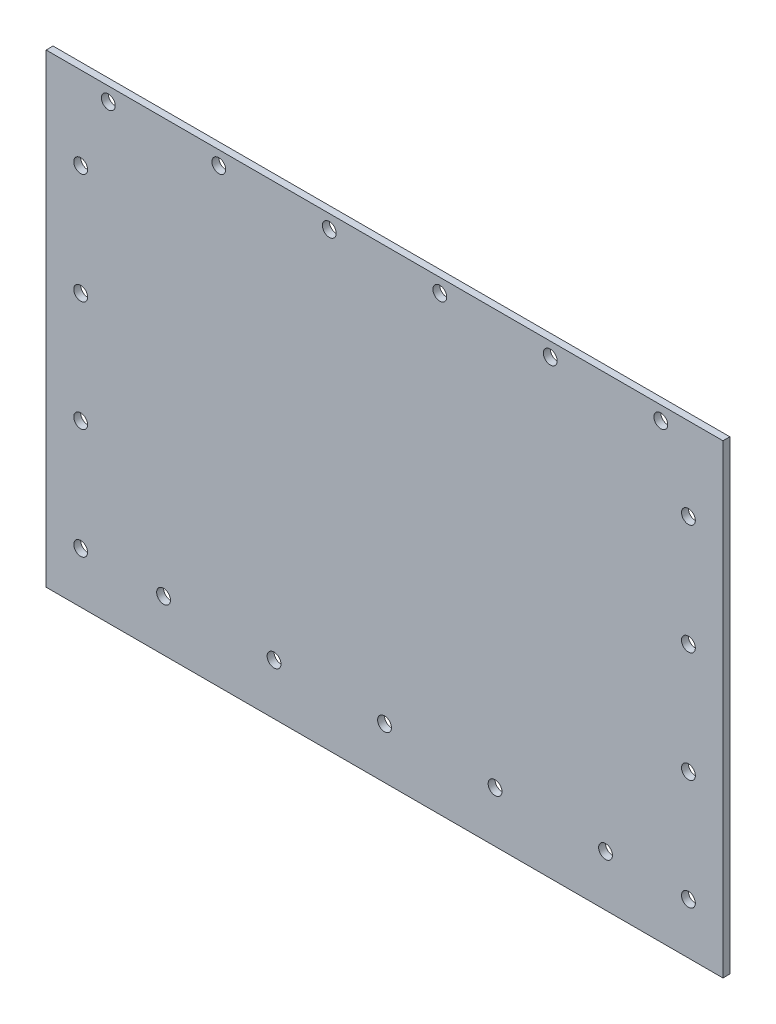
from build123d import *

# Parameters (mm, degrees)
SKETCH2_W           = 155.58
SKETCH2_H           = 106.95
SKETCH2_R           = 1.5875
BOSS_EXTRUDE2_DEPTH = 1.5875


with BuildPart() as part:
    # Sketch2 → Boss-Extrude2 (new body)
    with BuildSketch(Plane.XY):
        with Locations((77.79, -53.475)):
            Rectangle(SKETCH2_W, SKETCH2_H)
        with Locations((7.94, -95.25)):
            Circle(SKETCH2_R, mode=Mode.SUBTRACT)
        with Locations((7.94, -69.85)):
            Circle(SKETCH2_R, mode=Mode.SUBTRACT)
        with Locations((26.99, -95.25)):
            Circle(SKETCH2_R, mode=Mode.SUBTRACT)
        with Locations((52.39, -95.25)):
            Circle(SKETCH2_R, mode=Mode.SUBTRACT)
        with Locations((77.79, -95.25)):
            Circle(SKETCH2_R, mode=Mode.SUBTRACT)
        with Locations((7.94, -44.45)):
            Circle(SKETCH2_R, mode=Mode.SUBTRACT)
        with Locations((7.94, -19.05)):
            Circle(SKETCH2_R, mode=Mode.SUBTRACT)
        with Locations((14.29, -3.175)):
            Circle(SKETCH2_R, mode=Mode.SUBTRACT)
        with Locations((39.69, -3.175)):
            Circle(SKETCH2_R, mode=Mode.SUBTRACT)
        with Locations((65.09, -3.175)):
            Circle(SKETCH2_R, mode=Mode.SUBTRACT)
        with Locations((103.19, -95.25)):
            Circle(SKETCH2_R, mode=Mode.SUBTRACT)
        with Locations((128.59, -95.25)):
            Circle(SKETCH2_R, mode=Mode.SUBTRACT)
        with Locations((147.64, -95.25)):
            Circle(SKETCH2_R, mode=Mode.SUBTRACT)
        with Locations((147.64, -69.85)):
            Circle(SKETCH2_R, mode=Mode.SUBTRACT)
        with Locations((90.49, -3.175)):
            Circle(SKETCH2_R, mode=Mode.SUBTRACT)
        with Locations((115.89, -3.175)):
            Circle(SKETCH2_R, mode=Mode.SUBTRACT)
        with Locations((147.64, -44.45)):
            Circle(SKETCH2_R, mode=Mode.SUBTRACT)
        with Locations((147.64, -19.05)):
            Circle(SKETCH2_R, mode=Mode.SUBTRACT)
        with Locations((141.29, -3.175)):
            Circle(SKETCH2_R, mode=Mode.SUBTRACT)
    extrude(amount=BOSS_EXTRUDE2_DEPTH)


solid = part.part
